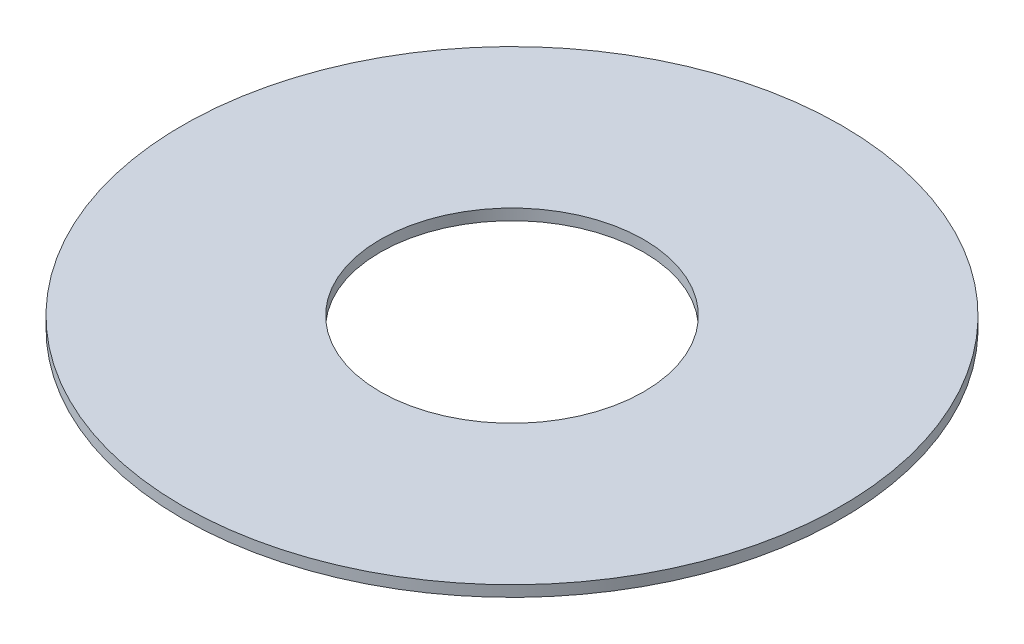
from build123d import *

# Parameters (mm, degrees)
SKETCH1_R      = 3
SKETCH1_R_2    = 1.2
EXTRUDE1_DEPTH = 0.1


with BuildPart() as part:
    # Sketch1 → Extrude1 (new body)
    with BuildSketch(Plane(origin=(0, 0, 0), x_dir=(1, 0, 0), z_dir=(0, 1, 0))):
        with Locations(Location((0, 0, 0), (0, 0, 270))):  # turned: the seam where the file's is
            Circle(SKETCH1_R)
        with Locations(Location((0, 0, 0), (0, 0, 270))):  # turned: the seam where the file's is
            Circle(SKETCH1_R_2, mode=Mode.SUBTRACT)
    extrude(amount=EXTRUDE1_DEPTH)


solid = part.part
